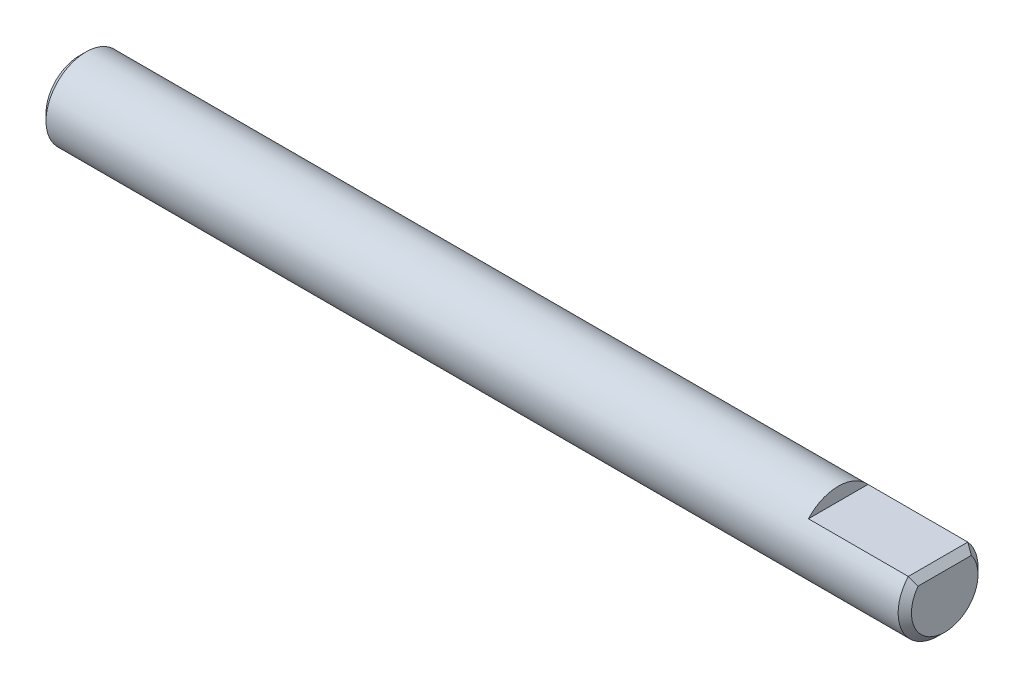
from build123d import *

# Parameters (mm, degrees)
SKETCH1_R           = 3
BOSS_EXTRUDE1_DEPTH = 32.5
CUT_EXTRUDE1_DEPTH  = 8
CHAMFER1_SIZE       = 0.5


with BuildPart() as part:
    # Sketch1 → Boss-Extrude1 (new body, symmetric)
    with BuildSketch(Plane(origin=(0, 0, 0), x_dir=(0, 0, -1), z_dir=(1, 0, 0))):
        Circle(SKETCH1_R)
    extrude(amount=BOSS_EXTRUDE1_DEPTH, both=True)

    # Sketch2 → Cut-Extrude1 (cut)
    with BuildSketch(Plane(origin=(32.5, 0, 0), x_dir=(0, 0, -1), z_dir=(1, 0, 0))):
        with BuildLine():
            Line((-2.236067977, 2), (2.236067977, 2))
            ThreePointArc((2.236067977, 2), (0, 3), (-2.236067977, 2))
        make_face()
    extrude(amount=-CUT_EXTRUDE1_DEPTH, mode=Mode.SUBTRACT)

    # Chamfer1
    chamfer1_edges = [part.edges().sort_by_distance(p)[0] for p in [
        (-32.5, 0, 3),
        (32.5, -2.802517077, 1.070466269),
        (32.5, 2, 0),
    ]]
    chamfer(chamfer1_edges, length=CHAMFER1_SIZE)


solid = part.part
